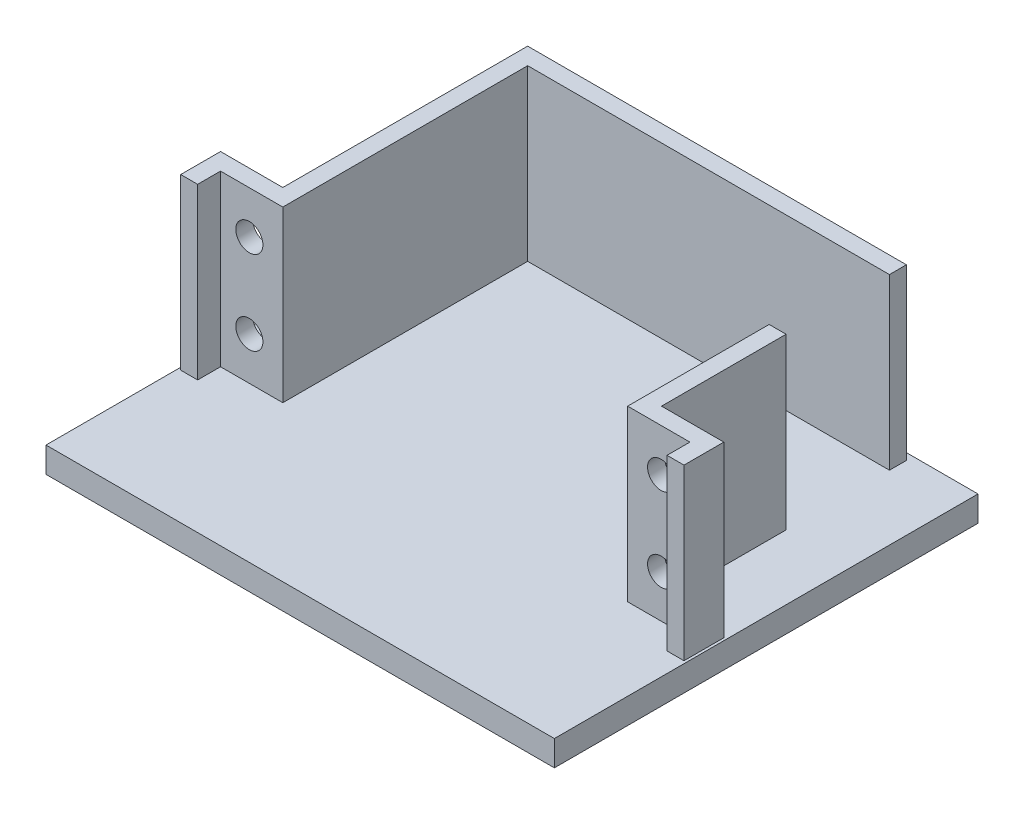
from build123d import *

# Parameters (mm, degrees)
BOSS_EXTRUDE2_DEPTH   = 20
BOSS_EXTRUDE2_2_DEPTH = 20
SKETCH3_W             = 60
SKETCH3_H             = 50
BOSS_EXTRUDE3_DEPTH   = 3
SKETCH4_R             = 1.6
CUT_EXTRUDE1_DEPTH    = 10


with BuildPart() as part:
    # Sketch1 → Boss-Extrude2 (new body)
    with BuildSketch(Plane(origin=(0, 0, 0), x_dir=(1, 0, 0), z_dir=(0, 1, 0))):
        Polygon((-20.35, 22.2), (22.35, 22.2), (22.35, 24.2), (-22.35, 24.2), (-22.35, -4.7), (-29.7, -4.7), (-29.7, -9.4), (-27.7, -9.4), (-27.7, -6.7), (-20.35, -6.7), align=None)
    extrude(amount=BOSS_EXTRUDE2_DEPTH)



with BuildPart() as body_2:
    # Sketch1 → Boss-Extrude2 2 (new body)
    with BuildSketch(Plane(origin=(0, 0, 0), x_dir=(1, 0, 0), z_dir=(0, 1, 0))):
        Polygon((20.35, -6.7), (20.35, 10), (22.35, 10), (22.35, -4.7), (29.7, -4.7), (29.7, -9.4), (27.7, -9.4), (27.7, -6.7), align=None)
    extrude(amount=BOSS_EXTRUDE2_2_DEPTH)


with BuildPart() as part_1:
    add(part.part)

    add(body_2.part)  # Boss-Extrude3 merges body 2
    # Sketch3 → Boss-Extrude3 (add)
    with BuildSketch(Plane(origin=(0, 0, 0), x_dir=(1, 0, 0), z_dir=(0, 1, 0))):
        Rectangle(SKETCH3_W, SKETCH3_H)
    extrude(amount=-BOSS_EXTRUDE3_DEPTH)

    # Sketch4 → Cut-Extrude1 (cut)
    with BuildSketch(Plane.XY):
        with Locations((-24.3, 14.95)):
            Circle(SKETCH4_R)
        with Locations((24.3, 14.95)):
            Circle(SKETCH4_R)
        with Locations((24.3, 5.05)):
            Circle(SKETCH4_R)
        with Locations((-24.3, 5.05)):
            Circle(SKETCH4_R)
    extrude(amount=CUT_EXTRUDE1_DEPTH, mode=Mode.SUBTRACT)


solid = part_1.part
